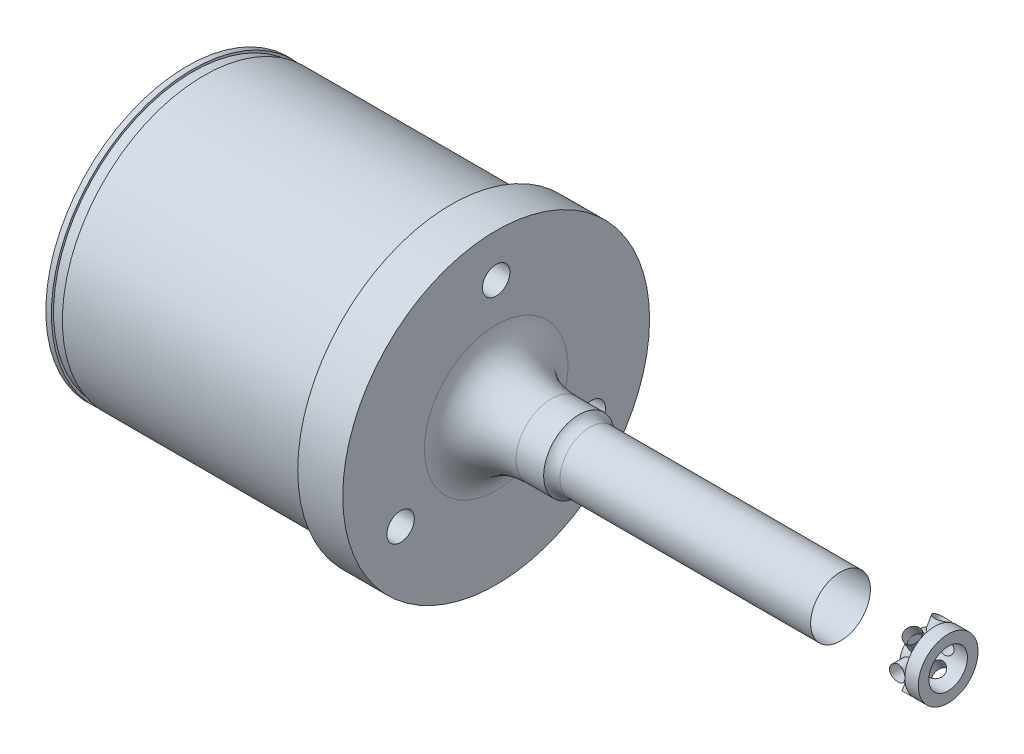
from build123d import *

# Parameters (mm, degrees)
SKETCH4_R              = 3.1623
DOWEL_PIN_HOLE_DEPTH   = 72.12
CIRPATTERN1_COUNT      = 3
SKETCH9_R              = 1.778
COTTER_PIN_HOLE_DEPTH  = 27.94
CIRPATTERN3_COUNT      = 3
SKETCH10_R             = 4.445
SHANK_TIP_RELIEF_DEPTH = 6.731


with BuildPart() as part:
    # Sketch1 → Base Revolve (revolve)
    with BuildSketch(Plane.XY):
        with BuildLine():
            Line((0, 16.51), (0, 35.306))
            Line((0, 35.306), (-10.3632, 35.306))
            Line((-10.3632, 35.306), (-10.3632, 32.766))
            Line((-10.3632, 32.766), (-71.12, 32.766))
            Line((-71.12, 32.766), (-71.12, 0))
            Line((-71.12, 0), (104.013, 0))
            Line((104.013, 0), (104.013, 6.8834))
            Line((104.013, 6.8834), (21.570750055, 6.8834))
            ThreePointArc((21.570750055, 6.8834), (20.165117635, 7.211503005), (19.05, 8.128))
            Line((19.05, 8.128), (12.7, 8.128))
            add(Edge.make_bspline(
                [(0, 16.51), (0, 8.128), (12.7, 8.128)],
                knots=[3.141592654, 3.141592654, 3.141592654, 4.71238898, 4.71238898, 4.71238898], degree=2, weights=[1, 0.707106781, 1]))
        make_face()
    revolve(axis=Axis((-132.525970605, 0, 0), (1, 0, 0)))

    # Sketch4 → Dowel Pin Hole (cut, through all)
    with BuildSketch(Plane(origin=(0, 0, 0), x_dir=(0, 0, -1), z_dir=(1, 0, 0))):
        with Locations((0, 25.4)):
            Circle(SKETCH4_R)
    dowel_pin_hole = extrude(amount=-DOWEL_PIN_HOLE_DEPTH, mode=Mode.SUBTRACT)

    # CirPattern1: Dowel Pin Hole ×3 about axis
    cirpattern1_axis = Axis((0, 0, 0), (1, 0, 0))
    for i in range(1, CIRPATTERN1_COUNT):
        add(dowel_pin_hole.rotate(cirpattern1_axis, i * 360 / CIRPATTERN1_COUNT), mode=Mode.SUBTRACT)

    # Sketch9 → Cotter Pin Hole (cut, symmetric)
    with BuildSketch(Plane.XY):
        with Locations((99.1616, 0)):
            Circle(SKETCH9_R)
    cotter_pin_hole = extrude(amount=COTTER_PIN_HOLE_DEPTH, both=True, mode=Mode.SUBTRACT)

    # CirPattern3: Cotter Pin Hole ×3 about axis
    cirpattern3_axis = Axis((116.645541128, 0, 0), (-1, 0, 0))
    for i in range(1, CIRPATTERN3_COUNT):
        add(cotter_pin_hole.rotate(cirpattern3_axis, i * 360 / CIRPATTERN3_COUNT), mode=Mode.SUBTRACT)

    # Sketch10 → Shank Tip Relief (cut)
    with BuildSketch(Plane(origin=(104.013, 0, 0), x_dir=(0, 0, -1), z_dir=(1, 0, 0))):
        Circle(SKETCH10_R)
    extrude(amount=-SHANK_TIP_RELIEF_DEPTH, mode=Mode.SUBTRACT)

    # Sketch14 → Inside Cut (revolve, cut)
    with BuildSketch(Plane.XY):
        Polygon((-5.08, 0), (-5.08, 22.987), (-30.48, 30.607), (-71.12, 30.607), (-71.12, 0), align=None)
    revolve(axis=Axis((116.645541128, 0, 0), (-1, 0, 0)), mode=Mode.SUBTRACT)

    # Sketch7 → Axle Relief (revolve, cut)
    with BuildSketch(Plane.XY):
        with BuildLine():
            Line((-5.08, 0), (-5.08, 13.28592398))
            ThreePointArc((-5.08, 13.28592398), (-2.803770837, 6.815535195), (-2.032, 0))
            Line((-2.032, 0), (-5.08, 0))
        make_face()
    revolve(axis=Axis((-5.08, 0, 0), (-1, 0, 0)), mode=Mode.SUBTRACT)

    # Sketch11 → Final Cut (revolve, cut)
    with BuildSketch(Plane.XY):
        with BuildLine():
            Line((-10.3632, 34.382877289), (-10.3632, 35.306))
            Line((-10.3632, 35.306), (-71.12, 35.306))
            Line((-71.12, 35.306), (-71.12, 32.51835))
            Line((-71.12, 32.51835), (-69.85, 32.51835))
            Line((-69.85, 32.51835), (-69.85, 32.01035))
            Line((-69.85, 32.01035), (-67.31, 32.01035))
            Line((-67.31, 32.01035), (-67.31, 32.51835))
            Line((-67.31, 32.51835), (-10.922, 32.51835))
            ThreePointArc((-10.922, 32.51835), (-9.948768341, 33.24267186), (-10.3632, 34.382877289))
        make_face()
    revolve(axis=Axis((116.645541128, 0, 0), (-1, 0, 0)), mode=Mode.SUBTRACT)


solid = part.part
